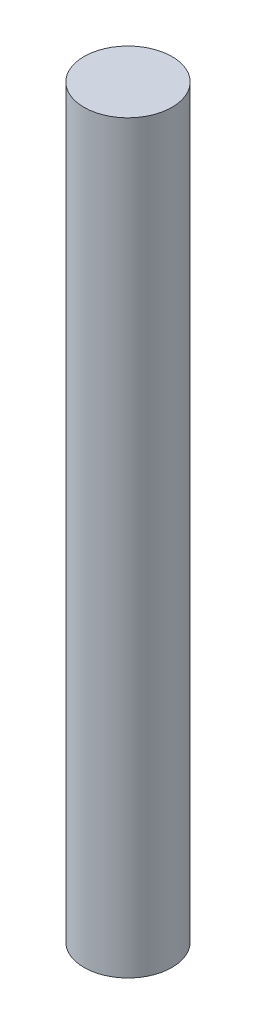
from build123d import *

# Parameters (mm, degrees)
SKETCH1_R           = 3
BOSS_EXTRUDE1_DEPTH = 25.4


with BuildPart() as part:
    # Sketch1 → Boss-Extrude1 (new body, symmetric)
    with BuildSketch(Plane(origin=(0, 0, 0), x_dir=(1, 0, 0), z_dir=(0, 1, 0))):
        Circle(SKETCH1_R)
    extrude(amount=BOSS_EXTRUDE1_DEPTH, both=True)


solid = part.part
